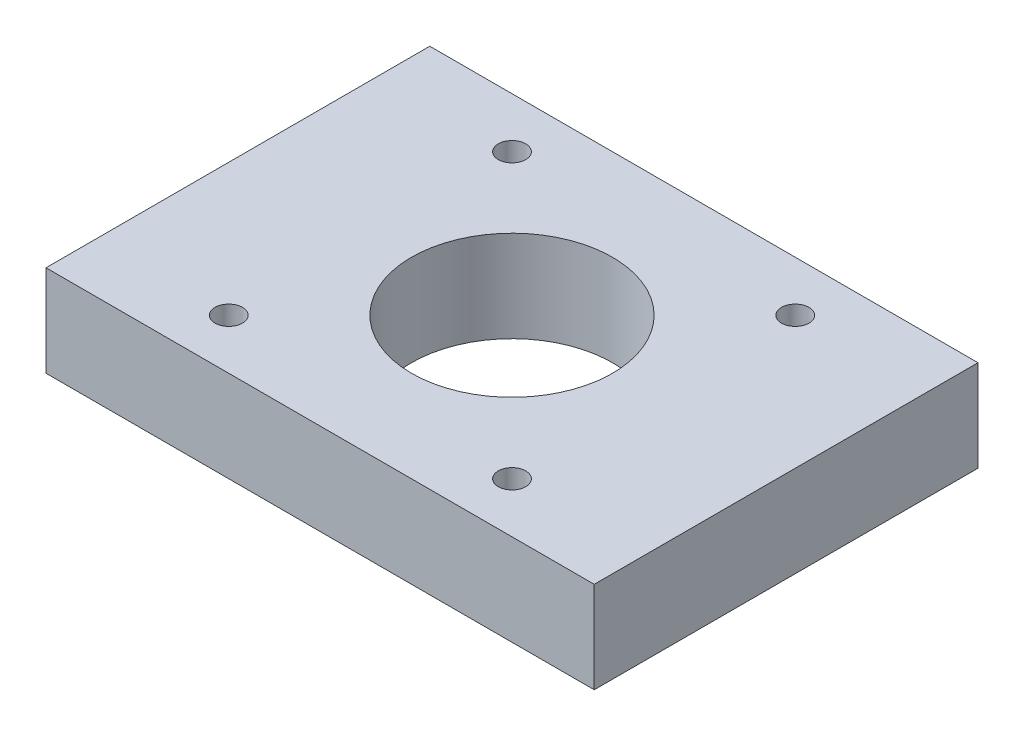
from build123d import *

# Parameters (mm, degrees)
SKETCH1_W           = 60
SKETCH1_H           = 10
BOSS_EXTRUDE1_DEPTH = 42
SKETCH2_R           = 11
SKETCH2_R_2         = 1.5
CUT_EXTRUDE1_DEPTH  = 11
SKETCH3_R           = 2.85
CUT_EXTRUDE2_DEPTH  = 3


with BuildPart() as part:
    # Sketch1 → Boss-Extrude1 (new body)
    with BuildSketch(Plane.XY):
        with Locations((0, 57.771455045)):
            Rectangle(SKETCH1_W, SKETCH1_H)
    extrude(amount=BOSS_EXTRUDE1_DEPTH)

    # Sketch2 → Cut-Extrude1 (cut, through all)
    with BuildSketch(Plane(origin=(0, 62.771455045, 0), x_dir=(1, 0, 0), z_dir=(0, 1, 0))):
        with Locations((0, -21)):
            Circle(SKETCH2_R)
        with Locations((-15.5, -36.5)):
            Circle(SKETCH2_R_2)
        with Locations((15.5, -36.5)):
            Circle(SKETCH2_R_2)
        with Locations((-15.5, -5.5)):
            Circle(SKETCH2_R_2)
        with Locations((15.5, -5.5)):
            Circle(SKETCH2_R_2)
    extrude(amount=-CUT_EXTRUDE1_DEPTH, mode=Mode.SUBTRACT)

    # Sketch3 → Cut-Extrude2 (cut)
    with BuildSketch(Plane.XZ.offset(-52.771455045)):
        with Locations((-15.5, 36.5)):
            Circle(SKETCH3_R)
        with Locations((15.5, 36.5)):
            Circle(SKETCH3_R)
        with Locations((15.5, 5.5)):
            Circle(SKETCH3_R)
        with Locations((-15.5, 5.5)):
            Circle(SKETCH3_R)
    extrude(amount=-CUT_EXTRUDE2_DEPTH, mode=Mode.SUBTRACT)


solid = part.part
